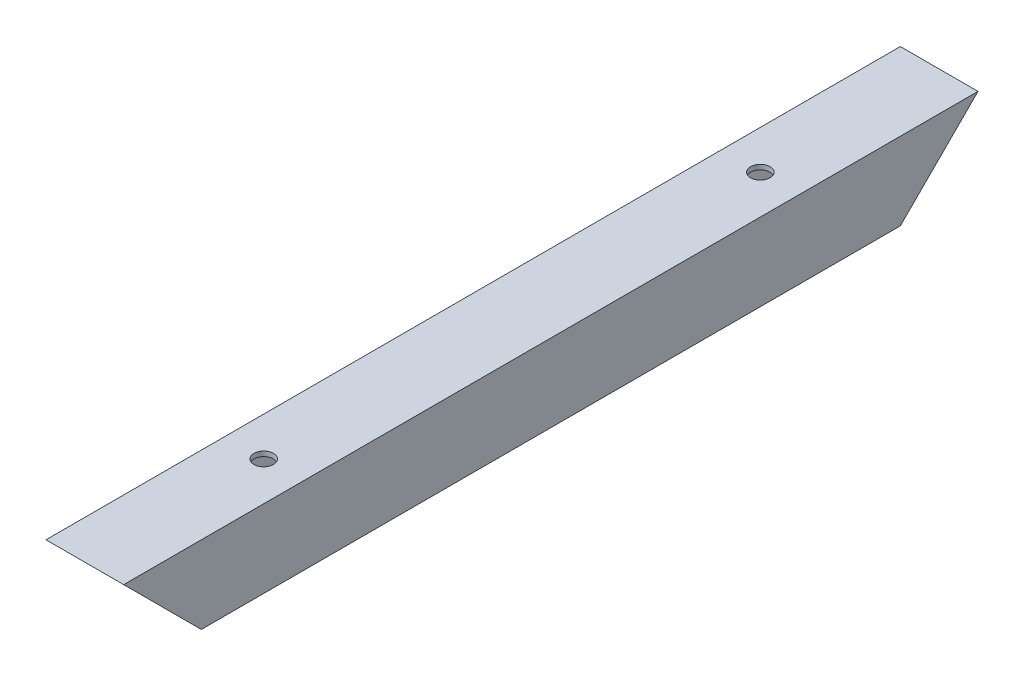
from build123d import *

# Parameters (mm, degrees)
SKETCH1_W           = 50.8
SKETCH1_H           = 50.8
SKETCH1_W_2         = 44.45
SKETCH1_H_2         = 44.45
EXTRUDE_THIN1_DEPTH = 279.4
CUT_EXTRUDE1_START  = -51.8
CUT_EXTRUDE1_DEPTH  = 52.8
SKETCH3_R           = 6.35
CUT_EXTRUDE2_DEPTH  = 51.8


with BuildPart() as part:
    # Sketch1 → Extrude-Thin1 (new body)
    with BuildSketch(Plane.XY.offset(91.6)):
        with Locations((514.35, 1092.2)):
            Rectangle(SKETCH1_W, SKETCH1_H)
        with Locations((514.35, 1092.2)):
            Rectangle(SKETCH1_W_2, SKETCH1_H_2, mode=Mode.SUBTRACT)
    extrude_thin1 = extrude(amount=EXTRUDE_THIN1_DEPTH)

    # Sketch2 → Cut-Extrude1 (cut)
    with BuildSketch(Plane(origin=(539.75, 0, 0), x_dir=(0, 0, -1), z_dir=(1, 0, 0)).offset(CUT_EXTRUDE1_START)):
        Polygon((-779.680330653, 1526.280330653), (-371, 1117.6), (-320.2, 1066.8), (88.480330653, 658.119669347), (-728.880330653, -159.24099196), (-1597.04099196, 708.919669347), align=None)
    cut_extrude1 = extrude(amount=CUT_EXTRUDE1_DEPTH, mode=Mode.SUBTRACT)

    # Sketch3 → Cut-Extrude2 (cut, through all)
    with BuildSketch(Plane(origin=(0, 1117.6, 0), x_dir=(1, 0, 0), z_dir=(0, 1, 0))):
        with Locations((514.35, -254)):
            Circle(SKETCH3_R)
        with Locations((507.848069556, 254)):
            Circle(SKETCH3_R)
    cut_extrude2 = extrude(amount=-CUT_EXTRUDE2_DEPTH, mode=Mode.SUBTRACT)

    # Mirror1: Extrude-Thin1, Cut-Extrude1, Cut-Extrude2 across plane
    add(extrude_thin1.mirror(Plane(origin=(488.95, 1066.8, 91.6), x_dir=(1, 0, 0), z_dir=(0, 0, 1))))
    add(cut_extrude1.mirror(Plane(origin=(488.95, 1066.8, 91.6), x_dir=(1, 0, 0), z_dir=(0, 0, 1))), mode=Mode.SUBTRACT)
    add(cut_extrude2.mirror(Plane(origin=(488.95, 1066.8, 91.6), x_dir=(1, 0, 0), z_dir=(0, 0, 1))), mode=Mode.SUBTRACT)


solid = part.part
